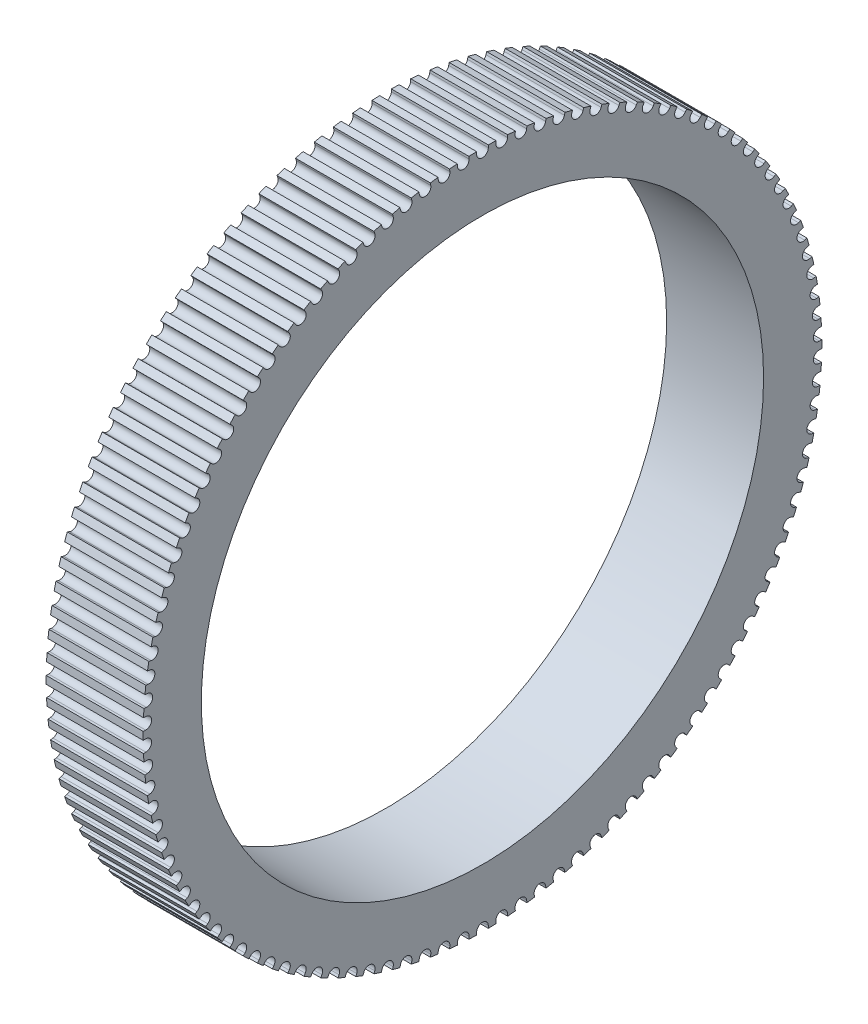
from build123d import *

# Parameters (mm, degrees)
SKETCH1_R           = 35
SKETCH1_R_2         = 29
BOSS_EXTRUDE1_DEPTH = 10
CUT_EXTRUDE1_DEPTH  = 10
CIRPATTERN1_COUNT   = 110


with BuildPart() as part:
    # Sketch1 → Boss-Extrude1 (new body)
    with BuildSketch(Plane(origin=(0, 0, 0), x_dir=(0, 0, -1), z_dir=(1, 0, 0))):
        Circle(SKETCH1_R)
        Circle(SKETCH1_R_2, mode=Mode.SUBTRACT)
    extrude(amount=BOSS_EXTRUDE1_DEPTH)

    # Sketch2 → Cut-Extrude1 (cut)
    with BuildSketch(Plane(origin=(10, 0, 0), x_dir=(0, 0, -1), z_dir=(1, 0, 0))):
        with BuildLine():
            Line((0.6, 36.500339377), (0.6, 34.747025064))
            ThreePointArc((0.6, 34.747025064), (0, 34.147025064), (-0.6, 34.747025064))
            Line((-0.6, 34.747025064), (-0.6, 36.500339377))
            ThreePointArc((-0.6, 36.500339377), (0, 37.100339377), (0.6, 36.500339377))
        make_face()
    cut_extrude1 = extrude(amount=-CUT_EXTRUDE1_DEPTH, mode=Mode.SUBTRACT)

    # CirPattern1: Cut-Extrude1 ×110 about axis
    cirpattern1_axis = Axis((0, 0, 0), (1, 0, 0))
    for i in range(1, CIRPATTERN1_COUNT):
        add(cut_extrude1.rotate(cirpattern1_axis, i * 360 / CIRPATTERN1_COUNT), mode=Mode.SUBTRACT)


solid = part.part
